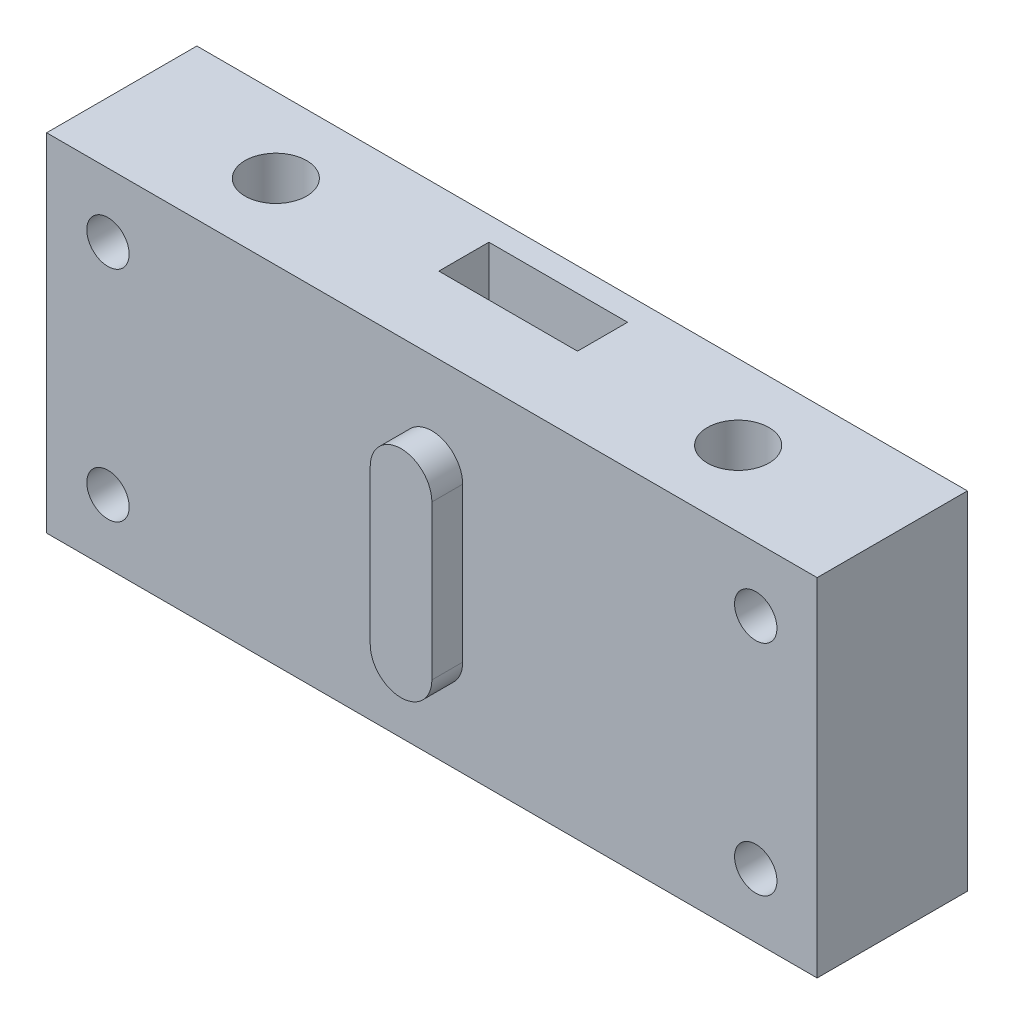
from build123d import *

# Parameters (mm, degrees)
SKETCH1_W           = 100
SKETCH1_H           = 45
BOSS_EXTRUDE1_DEPTH = 19.5
SKETCH2_R           = 4
CUT_EXTRUDE1_DEPTH  = 46
SKETCH4_R           = 2.75
CUT_EXTRUDE3_DEPTH  = 20.5
SKETCH5_W           = 18
SKETCH5_H           = 6.5
CUT_EXTRUDE5_DEPTH  = 46
SKETCH6_W           = 18
SKETCH6_H           = 10
CUT_EXTRUDE6_DEPTH  = 4
BOSS_EXTRUDE2_DEPTH = 4


with BuildPart() as part:
    # Sketch1 → Boss-Extrude1 (new body)
    with BuildSketch(Plane.XY):
        Rectangle(SKETCH1_W, SKETCH1_H)
    extrude(amount=BOSS_EXTRUDE1_DEPTH)

    # Sketch2 → Cut-Extrude1 (cut, through all)
    with BuildSketch(Plane(origin=(0, 22.5, 0), x_dir=(1, 0, 0), z_dir=(0, 1, 0))):
        with Locations((-30, -9.75)):
            Circle(SKETCH2_R)
        with Locations((30, -9.75)):
            Circle(SKETCH2_R)
    extrude(amount=-CUT_EXTRUDE1_DEPTH, mode=Mode.SUBTRACT)

    # Sketch4 → Cut-Extrude3 (cut, through all)
    with BuildSketch(Plane(origin=(0, 0, 0), x_dir=(-1, 0, 0), z_dir=(0, 0, -1))):
        with Locations((-42.034787685, 14.2)):
            Circle(SKETCH4_R)
        with Locations((-42.034787685, -14.2)):
            Circle(SKETCH4_R)
        with Locations((42.034787685, -14.2)):
            Circle(SKETCH4_R)
        with Locations((42.034787685, 14.2)):
            Circle(SKETCH4_R)
    extrude(amount=-CUT_EXTRUDE3_DEPTH, mode=Mode.SUBTRACT)

    # Sketch5 → Cut-Extrude5 (cut, through all)
    with BuildSketch(Plane(origin=(0, 22.5, 0), x_dir=(1, 0, 0), z_dir=(0, 1, 0))):
        with Locations((0, -6.35)):
            Rectangle(SKETCH5_W, SKETCH5_H)
    extrude(amount=-CUT_EXTRUDE5_DEPTH, mode=Mode.SUBTRACT)

    # Sketch6 → Cut-Extrude6 (cut)
    with BuildSketch(Plane(origin=(0, 0, 0), x_dir=(-1, 0, 0), z_dir=(0, 0, -1))):
        Rectangle(SKETCH6_W, SKETCH6_H)
    extrude(amount=-CUT_EXTRUDE6_DEPTH, mode=Mode.SUBTRACT)

    # Sketch7 → Boss-Extrude2 (add)
    with BuildSketch(Plane.XY.offset(19.5)):
        with BuildLine():
            Line((4, 10), (4, -10))
            ThreePointArc((4, -10), (0, -14), (-4, -10))
            Line((-4, -10), (-4, 10))
            ThreePointArc((-4, 10), (0, 14), (4, 10))
        make_face()
    extrude(amount=BOSS_EXTRUDE2_DEPTH)


solid = part.part
